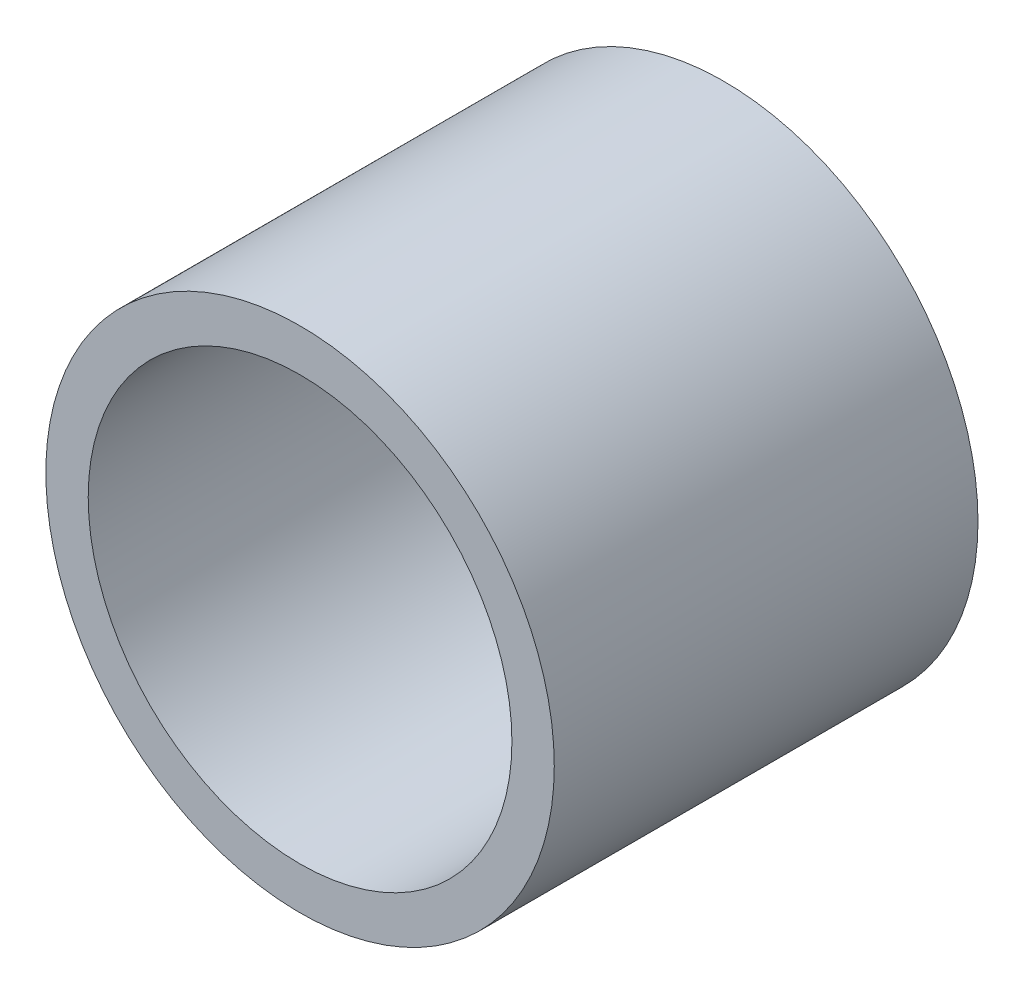
from build123d import *

# Parameters (mm, degrees)
SKETCH1_R           = 18
SKETCH1_R_2         = 15
EXTRUDE_THIN1_DEPTH = 15
SKETCH2_R           = 5
BOSS_EXTRUDE1_DEPTH = 10


with BuildPart() as part:
    # Sketch1 → Extrude-Thin1 (new body, symmetric)
    with BuildSketch(Plane.XY):
        Circle(SKETCH1_R)
        Circle(SKETCH1_R_2, mode=Mode.SUBTRACT)
    extrude(amount=EXTRUDE_THIN1_DEPTH, both=True)


with BuildPart() as body_2:
    # Sketch2 → Boss-Extrude1 (new body)
    with BuildSketch(Plane.XY):
        Circle(SKETCH2_R)
    extrude(amount=-BOSS_EXTRUDE1_DEPTH)


solid = Compound([part.part, body_2.part])
